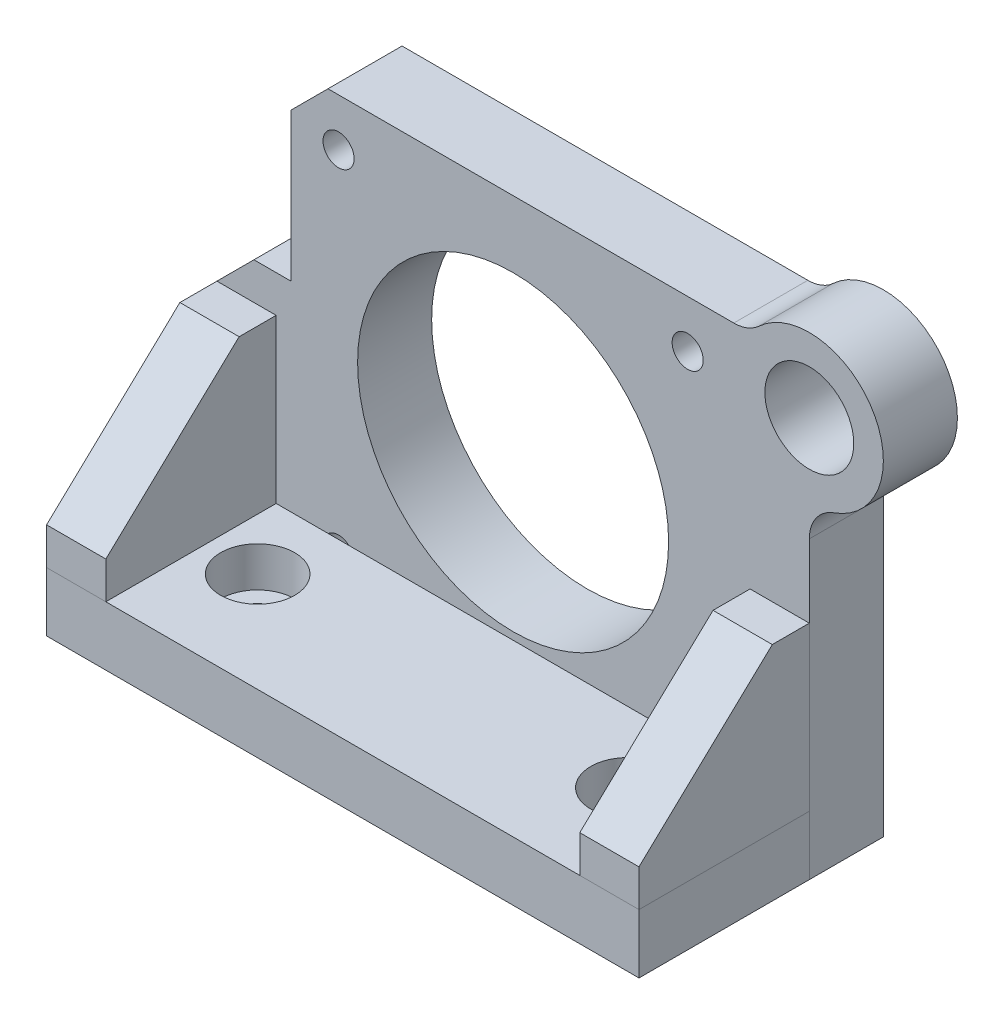
from build123d import *

# Parameters (mm, degrees)
SKETCH1_R                                    = 21
SKETCH1_R_2                                  = 6
EXTRUDE1_DEPTH                               = 10
M5_TAPPED_HOLE1_D                            = 4.2
SKETCH6_W                                    = 80
SKETCH6_H                                    = 23
EXTRUDE2_DEPTH                               = 8
CHAMFER1_SIZE                                = 5
EXTRUDE3_DEPTH                               = 8
EXTRUDE4_DEPTH                               = 8
CBORE_FOR_M5_HEX_SOCKET_HEAD_CAP_SCR_2_COUNT = 2
CBORE_FOR_M5_HEX_SOCKET_HEAD_CAP_SCR_2_PITCH = 50
FILLET1_R                                    = 5


with BuildPart() as part:
    # Sketch1 → Extrude1 (new body)
    with BuildSketch(Plane.XY):
        with BuildLine():
            Line((-30, 30), (32, 30))
            ThreePointArc((32, 30), (48.94427191, 28.472135955), (40, 14))
            Line((40, 14), (40, -30))
            Line((40, -30), (-40, -30))
            Line((-40, -30), (-40, 5))
            Line((-40, 5), (-30, 5))
            Line((-30, 5), (-30, 30))
        make_face()
        Circle(SKETCH1_R, mode=Mode.SUBTRACT)
        with Locations((40, 24)):
            Circle(SKETCH1_R_2, mode=Mode.SUBTRACT)
    extrude(amount=EXTRUDE1_DEPTH)

    # M5 Tapped Hole1 (through all)
    with Locations(Plane.XY.offset(10)):
        with Locations((-23.571404551, 23.571404551), (23.571404551, 23.571404551), (23.571404551, -23.571404551), (-23.571404551, -23.571404551)):
            Hole(M5_TAPPED_HOLE1_D / 2)

    # Chamfer1
    chamfer1_edges = [part.edges().sort_by_distance(p)[0] for p in [
        (-30, 30, 5),
        (-40, 5, 5),
    ]]
    chamfer(chamfer1_edges, length=CHAMFER1_SIZE)

    # Fillet1
    fillet1_edges = [part.edges().sort_by_distance(p)[0] for p in [
        (32, 30, 5),
        (40, 14, 5),
    ]]
    fillet(fillet1_edges, radius=FILLET1_R)


with BuildPart() as body_2:
    # Sketch6 → Extrude2 (new body)
    with BuildSketch(Plane.XZ.offset(30)):
        with Locations((0, 21.5)):
            Rectangle(SKETCH6_W, SKETCH6_H)
    extrude(amount=-EXTRUDE2_DEPTH)

    # Sketch10 → CBORE for M5 Hex Socket Head Cap Screw1 (revolve, cut)
    with BuildSketch(Plane(origin=(25, -22, 19.5), x_dir=(0, 0, 1), z_dir=(1, 0, 0))):
        Polygon((0, 0), (0, 8), (2.75, 8), (2.75, 5.4), (5, 5.4), (5, 0), align=None)
    cbore_for_m5_hex_socket_head_cap_screw1 = revolve(axis=Axis((25, -15.65, 19.5), (0, -1, 0)), mode=Mode.SUBTRACT)

    # CBORE for M5 Hex Socket Head Cap Scr 2: CBORE for M5 Hex Socket Head Cap Screw1 ×2
    with Locations(*[(-i * CBORE_FOR_M5_HEX_SOCKET_HEAD_CAP_SCR_2_PITCH, 0, 0) for i in range(1, CBORE_FOR_M5_HEX_SOCKET_HEAD_CAP_SCR_2_COUNT)]):
        add(cbore_for_m5_hex_socket_head_cap_screw1, mode=Mode.SUBTRACT)


with BuildPart() as body_3:
    # Sketch7 → Extrude3 (new body)
    with BuildSketch(Plane(origin=(40, 0, 0), x_dir=(0, 0, -1), z_dir=(1, 0, 0))):
        Polygon((-10, 0), (-15, 0), (-33, -17), (-33, -22), (-10, -22), align=None)
    extrude(amount=-EXTRUDE3_DEPTH)


with BuildPart() as body_4:
    # Sketch8 → Extrude4 (new body)
    with BuildSketch(Plane.ZY.offset(40)):
        Polygon((15, 0), (10, 0), (10, -22), (33, -22), (33, -17), align=None)
    extrude(amount=-EXTRUDE4_DEPTH)


solid = Compound([part.part, body_2.part, body_3.part, body_4.part])
